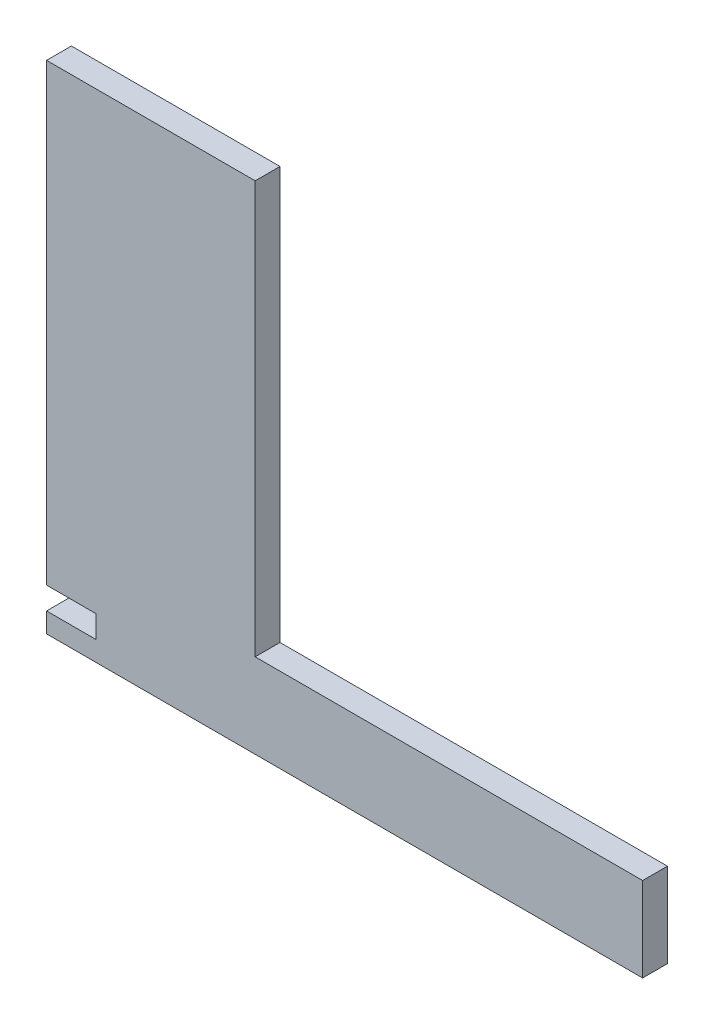
from build123d import *

# Parameters (mm, degrees)
AUFSATZ_LINEAR_AUSTRAGEN1_DEPTH = 5


with BuildPart() as part:
    # Skizze1 → Aufsatz-Linear austragen1 (new body)
    with BuildSketch(Plane.XY):
        Polygon((-9.108910891, 5.52970297), (-9.108910891, 1.02970297), (-19.108910891, 1.02970297), (-19.108910891, -2.97029703), (100.891089109, -2.97029703), (100.891089109, 14.02970297), (22.891089109, 14.02970297), (22.891089109, 97.02970297), (-19.108910891, 97.02970297), (-19.108910891, 5.52970297), align=None)
    extrude(amount=AUFSATZ_LINEAR_AUSTRAGEN1_DEPTH)


solid = part.part
